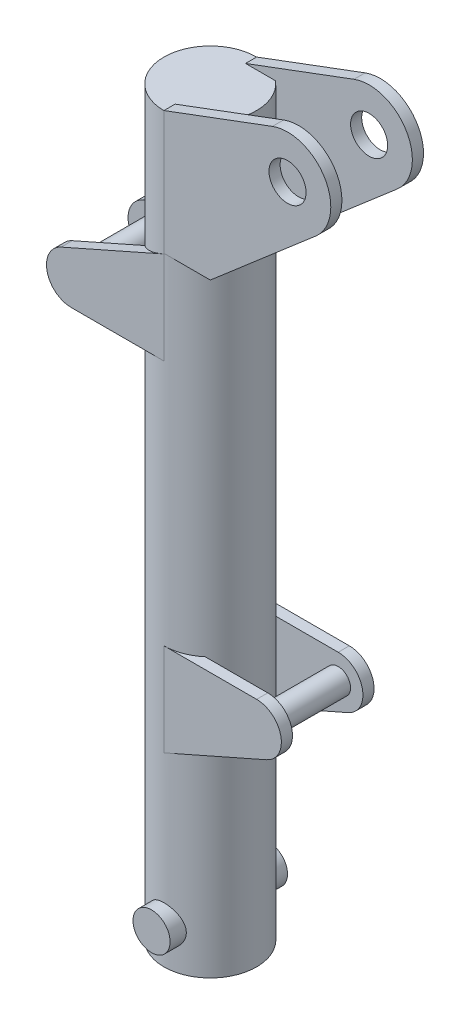
from build123d import *

# Parameters (mm, degrees)
SKETCH2_R           = 75
BOSS_EXTRUDE1_DEPTH = 1200
SHELL4_T            = 10
BOSS_EXTRUDE2_START = 75
SKETCH3_R           = 30
BOSS_EXTRUDE2_DEPTH = 18
SKETCH10_R          = 30
BOSS_EXTRUDE3_DEPTH = 95
SKETCH12_R          = 20
BOSS_EXTRUDE4_DEPTH = 75


with BuildPart() as part:
    # Sketch2 → Boss-Extrude1 (new body)
    with BuildSketch(Plane(origin=(0, 0, 0), x_dir=(1, 0, 0), z_dir=(0, 1, 0))):
        Circle(SKETCH2_R)
    extrude(amount=BOSS_EXTRUDE1_DEPTH)

    # Shell4 (no face opened: a closed hollow body)
    add(offset(amount=-SHELL4_T, mode=Mode.PRIVATE), mode=Mode.SUBTRACT)

    # Sketch3 → Boss-Extrude2 (add)
    with BuildSketch(Plane.XY.offset(BOSS_EXTRUDE2_START)):
        with BuildLine():
            Line((0, 450), (150, 450))
            ThreePointArc((150, 450), (189.137774485, 418.260424226), (166.164731025, 373.41173042))
            Line((166.164731025, 373.41173042), (0, 300))
            Line((0, 300), (0, 450))
        make_face()
        with BuildLine():
            Line((0, 999), (0, 849))
            Line((0, 849), (-150, 849))
            ThreePointArc((-150, 849), (-189.137774485, 880.739575774), (-166.164731025, 925.58826958))
            Line((-166.164731025, 925.58826958), (0, 999))
        make_face()
        with BuildLine():
            Line((0, 1000), (0, 1200))
            Line((0, 1200), (175.5, 1265.572478983))
            ThreePointArc((175.5, 1265.572478983), (260.246822056, 1235.64155485), (245.673880023, 1146.953824986))
            Line((245.673880023, 1146.953824986), (75, 1000))
            Line((75, 1000), (0, 1000))
        make_face()
        with Locations((200, 1200)):
            Circle(SKETCH3_R, mode=Mode.SUBTRACT)
    boss_extrude2 = extrude(amount=-BOSS_EXTRUDE2_DEPTH)

    # Mirror11: Boss-Extrude2 across plane
    add(boss_extrude2.mirror(Plane(origin=(0, 0, 0), x_dir=(1, 0, 0), z_dir=(0, 0, -1))))

    # Sketch10 → Boss-Extrude3 (add, symmetric)
    with BuildSketch(Plane.XY):
        with Locations((0, 60)):
            Circle(SKETCH10_R)
    extrude(amount=BOSS_EXTRUDE3_DEPTH, both=True)

    # Sketch12 → Boss-Extrude4 (add, symmetric)
    with BuildSketch(Plane.XY):
        with Locations((150, 410)):
            Circle(SKETCH12_R)
        with Locations((-150, 889)):
            Circle(SKETCH12_R)
    extrude(amount=BOSS_EXTRUDE4_DEPTH, both=True)


solid = part.part
